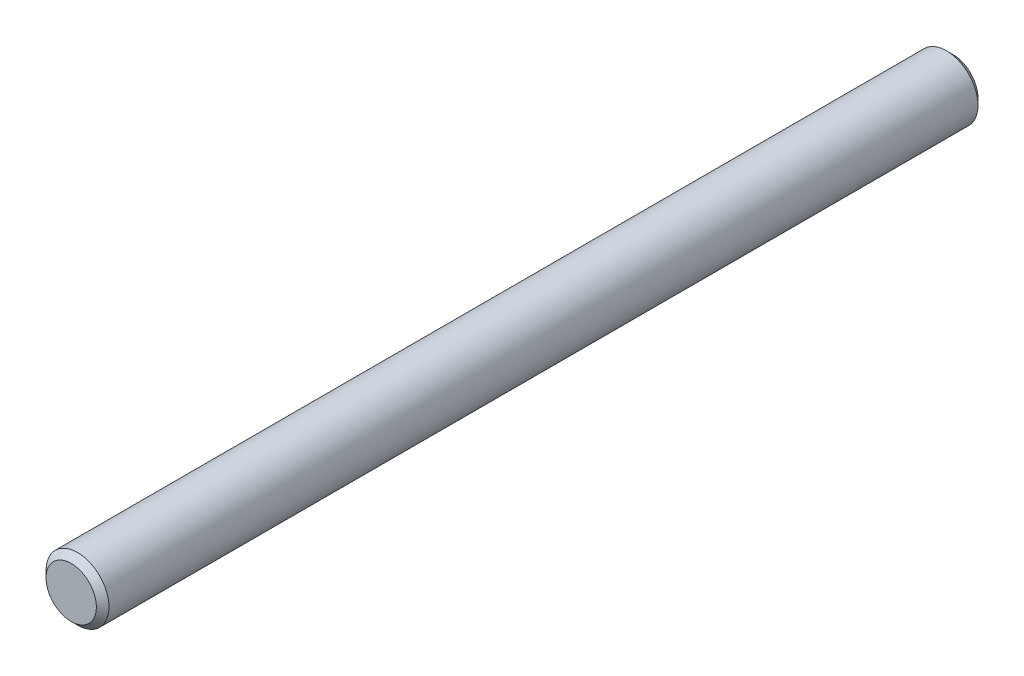
from build123d import *

# Parameters (mm, degrees)
SKETCH_1_R      = 2.5
EXTRUDE_1_DEPTH = 70
CHAMFER_1_SIZE  = 0.5


with BuildPart() as part:
    # 草图1 → 凸台-拉伸1 (new body)
    with BuildSketch(Plane.XY):
        Circle(SKETCH_1_R)
    extrude(amount=EXTRUDE_1_DEPTH)

    # 倒角1
    chamfer_1_edges = [part.edges().sort_by_distance(p)[0] for p in [
        (-2.5, 0, 0),
        (-2.5, 0, 70),
    ]]
    chamfer(chamfer_1_edges, length=CHAMFER_1_SIZE)


solid = part.part
